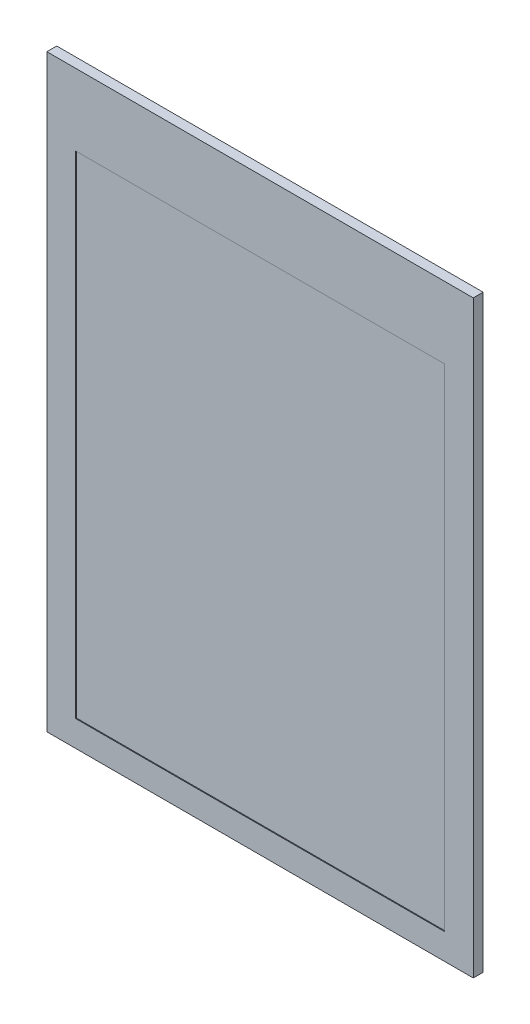
from build123d import *

# Parameters (mm, degrees)
SKETCH1_W           = 49.9618
SKETCH1_H           = 69.0118
BOSS_EXTRUDE1_DEPTH = 1.1566
SKETCH3_W           = 43.199747393
SKETCH3_H           = 57.599795215
CUT_EXTRUDE1_DEPTH  = 0.1


with BuildPart() as part:
    # Sketch1 → Boss-Extrude1 (new body)
    with BuildSketch(Plane.XY.offset(8.79254995)):
        with Locations((2.257083431, -61.428094771)):
            Rectangle(SKETCH1_W, SKETCH1_H)
    extrude(amount=BOSS_EXTRUDE1_DEPTH)

    # Sketch3 → Cut-Extrude1 (cut)
    with BuildSketch(Plane.XY.offset(9.94914995)):
        with Locations((2.256996925, -64.104049821)):
            Rectangle(SKETCH3_W, SKETCH3_H)
    extrude(amount=-CUT_EXTRUDE1_DEPTH, mode=Mode.SUBTRACT)


solid = part.part
